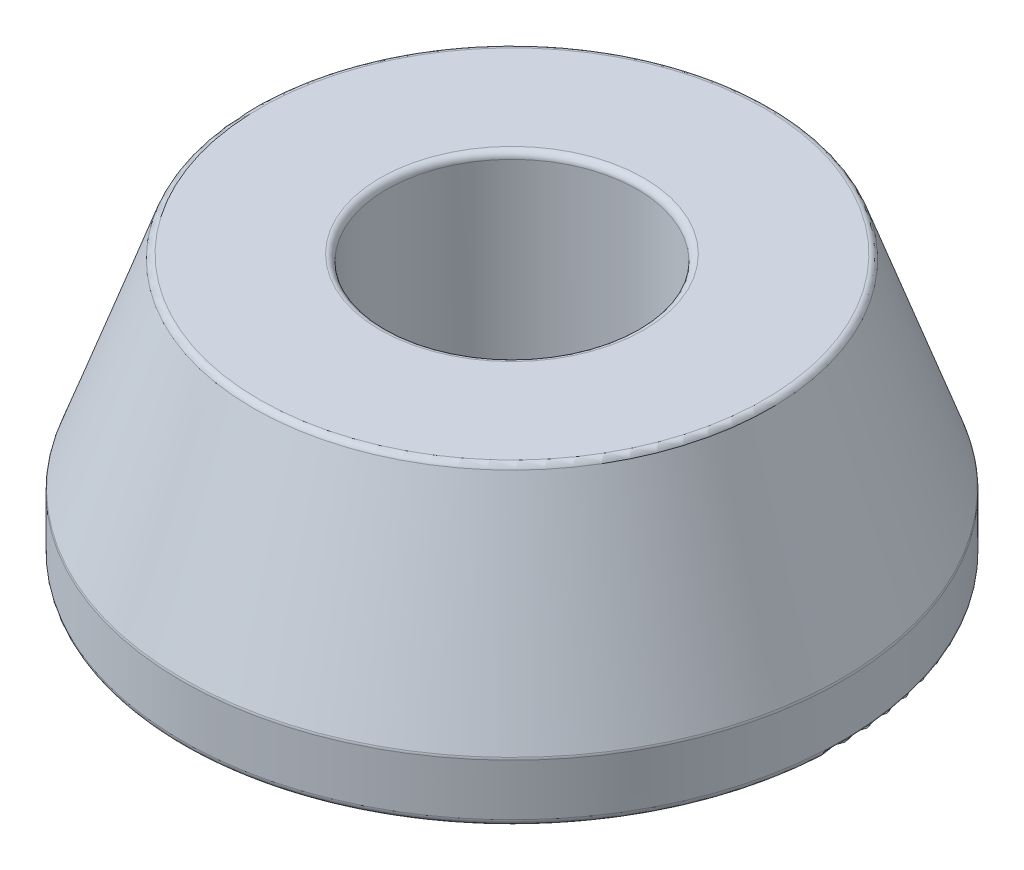
from build123d import *

# Parameters (mm, degrees)
FILLET1_R = 0.25


with BuildPart() as part:
    # Sketch1 → Revolve1 (revolve)
    with BuildSketch(Plane.XY):
        Polygon((4.75, 10), (9.75, 10), (12.5, 2.25), (12.5, 0), (4.75, 0), align=None)
    revolve(axis=Axis((0, 0, 0), (0, 1, 0)))

    # Fillet1
    fillet1_edges = [part.edges().sort_by_distance(p)[0] for p in [
        (-4.75, 0, 0),
        (-12.5, 0, 0),
        (-12.5, 2.25, 0),
        (-9.75, 10, 0),
        (-4.75, 10, 0),
    ]]
    fillet(fillet1_edges, radius=FILLET1_R)


solid = part.part
